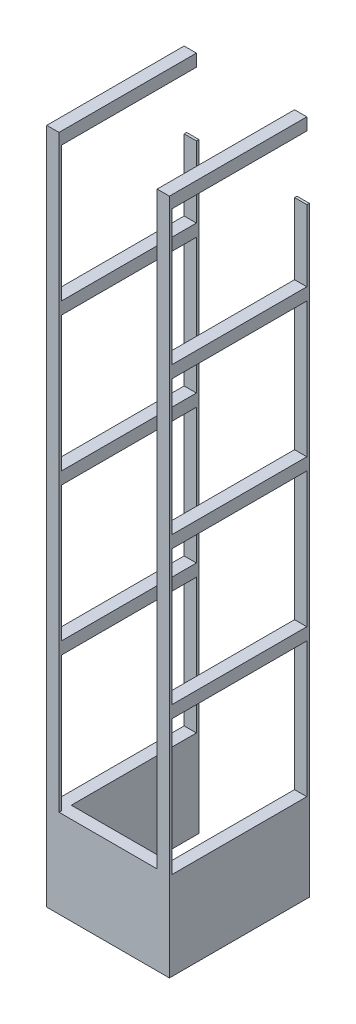
from build123d import *

# Parameters (mm, degrees)
SKETCH1_W            = 10
SKETCH1_H            = 2
BOSS_EXTRUDE1_DEPTH  = 112
SKETCH2_W            = 10
SKETCH2_H            = 2
BOSS_EXTRUDE2_DEPTH  = 480
SKETCH3_W            = 10
SKETCH3_H            = 2
BOSS_EXTRUDE3_DEPTH  = 90
SKETCH4_W            = 10
SKETCH4_H            = 2
BOSS_EXTRUDE4_DEPTH  = 102
SKETCH5_W            = 10
SKETCH5_H            = 2
BOSS_EXTRUDE5_DEPTH  = 480
SKETCH6_W            = 10
SKETCH6_H            = 10
BOSS_EXTRUDE6_DEPTH  = 110
SKETCH7_W            = 10
SKETCH7_H            = 10
BOSS_EXTRUDE7_DEPTH  = 110
SKETCH8_W            = 10
SKETCH8_H            = 10
BOSS_EXTRUDE8_DEPTH  = 110
SKETCH9_W            = 10
SKETCH9_H            = 10
BOSS_EXTRUDE9_DEPTH  = 110
BOSS_EXTRUDE10_DEPTH = 70
SKETCH12_W           = 10
SKETCH12_H           = 2
BOSS_EXTRUDE11_DEPTH = 490


with BuildPart() as part:
    # Sketch1 → Boss-Extrude1 (new body)
    with BuildSketch(Plane.XY):
        Rectangle(SKETCH1_W, SKETCH1_H)
    extrude(amount=BOSS_EXTRUDE1_DEPTH)

    # Sketch2 → Boss-Extrude2 (add)
    with BuildSketch(Plane(origin=(0, 1, 0), x_dir=(1, 0, 0), z_dir=(0, 1, 0))):
        with Locations((0, -111)):
            Rectangle(SKETCH2_W, SKETCH2_H)
    extrude(amount=BOSS_EXTRUDE2_DEPTH)

    # Sketch3 → Boss-Extrude3 (add)
    with BuildSketch(Plane(origin=(5, 0, 0), x_dir=(0, 0, -1), z_dir=(1, 0, 0))):
        with Locations((-107, 0)):
            Rectangle(SKETCH3_W, SKETCH3_H)
    extrude(amount=BOSS_EXTRUDE3_DEPTH)

    # Sketch4 → Boss-Extrude4 (add)
    with BuildSketch(Plane(origin=(0, 0, 102), x_dir=(-1, 0, 0), z_dir=(0, 0, -1))):
        with Locations((-90, 0)):
            Rectangle(SKETCH4_W, SKETCH4_H)
    extrude(amount=BOSS_EXTRUDE4_DEPTH)

    # Sketch5 → Boss-Extrude5 (add)
    with BuildSketch(Plane(origin=(0, 1, 0), x_dir=(1, 0, 0), z_dir=(0, 1, 0))):
        with Locations((90, -111)):
            Rectangle(SKETCH5_W, SKETCH5_H)
    extrude(amount=BOSS_EXTRUDE5_DEPTH)

    # Sketch6 → Boss-Extrude6 (add)
    with BuildSketch(Plane(origin=(0, 0, 110), x_dir=(-1, 0, 0), z_dir=(0, 0, -1))):
        with Locations((-90, 116)):
            Rectangle(SKETCH6_W, SKETCH6_H)
        with Locations((0, 116)):
            Rectangle(SKETCH6_W, SKETCH6_H)
    extrude(amount=BOSS_EXTRUDE6_DEPTH)

    # Sketch7 → Boss-Extrude7 (add)
    with BuildSketch(Plane(origin=(0, 0, 110), x_dir=(-1, 0, 0), z_dir=(0, 0, -1))):
        with Locations((-90, 236)):
            Rectangle(SKETCH7_W, SKETCH7_H)
        with Locations((0, 236)):
            Rectangle(SKETCH7_W, SKETCH7_H)
    extrude(amount=BOSS_EXTRUDE7_DEPTH)

    # Sketch8 → Boss-Extrude8 (add)
    with BuildSketch(Plane(origin=(0, 0, 110), x_dir=(-1, 0, 0), z_dir=(0, 0, -1))):
        with Locations((-90, 356)):
            Rectangle(SKETCH8_W, SKETCH8_H)
        with Locations((0, 356)):
            Rectangle(SKETCH8_W, SKETCH8_H)
    extrude(amount=BOSS_EXTRUDE8_DEPTH)

    # Sketch9 → Boss-Extrude9 (add)
    with BuildSketch(Plane(origin=(0, 0, 110), x_dir=(-1, 0, 0), z_dir=(0, 0, -1))):
        with Locations((-90, 476)):
            Rectangle(SKETCH9_W, SKETCH9_H)
        with Locations((0, 476)):
            Rectangle(SKETCH9_W, SKETCH9_H)
    extrude(amount=BOSS_EXTRUDE9_DEPTH)

    # Sketch11 → Boss-Extrude10 (add)
    with BuildSketch(Plane.XZ.offset(1)):
        Polygon((-5, 112), (-5, 0), (5, 0), (5, 102), (85, 102), (85, 0), (95, 0), (95, 112), align=None)
    extrude(amount=BOSS_EXTRUDE10_DEPTH)

    # Sketch12 → Boss-Extrude11 (add)
    with BuildSketch(Plane.XZ.offset(71)):
        with Locations((90, -1)):
            Rectangle(SKETCH12_W, SKETCH12_H)
        with Locations((0, -1)):
            Rectangle(SKETCH12_W, SKETCH12_H)
    extrude(amount=-BOSS_EXTRUDE11_DEPTH)


solid = part.part
